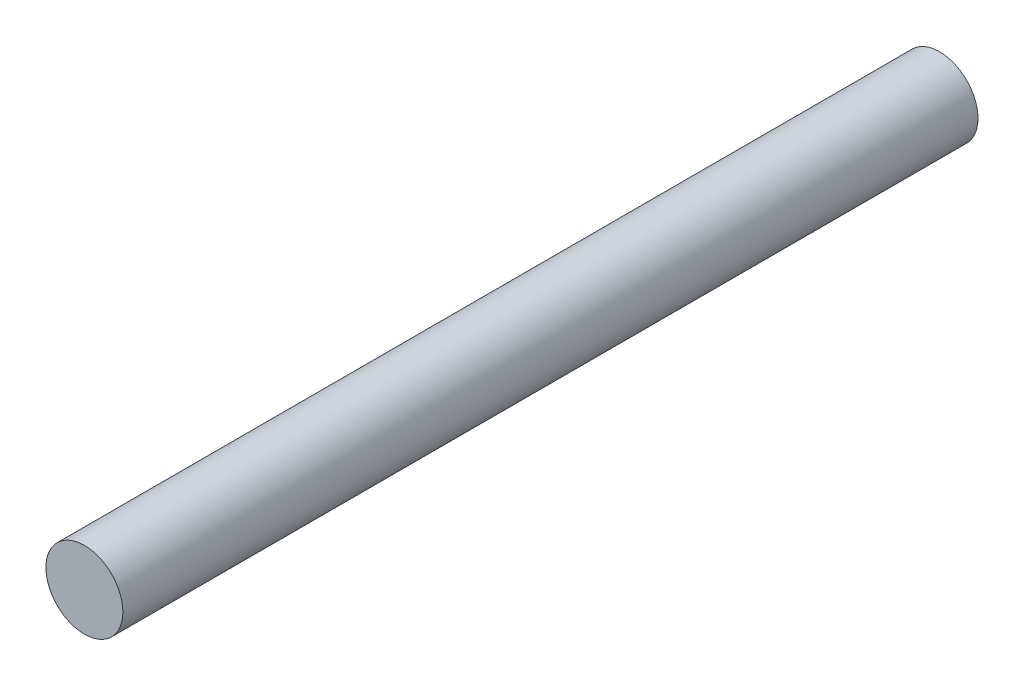
from build123d import *

# Parameters (mm, degrees)
SKETCH1_R           = 4.5
BOSS_EXTRUDE1_DEPTH = 100


with BuildPart() as part:
    # Sketch1 → Boss-Extrude1 (new body)
    with BuildSketch(Plane.XY):
        Circle(SKETCH1_R)
    extrude(amount=BOSS_EXTRUDE1_DEPTH)


solid = part.part
